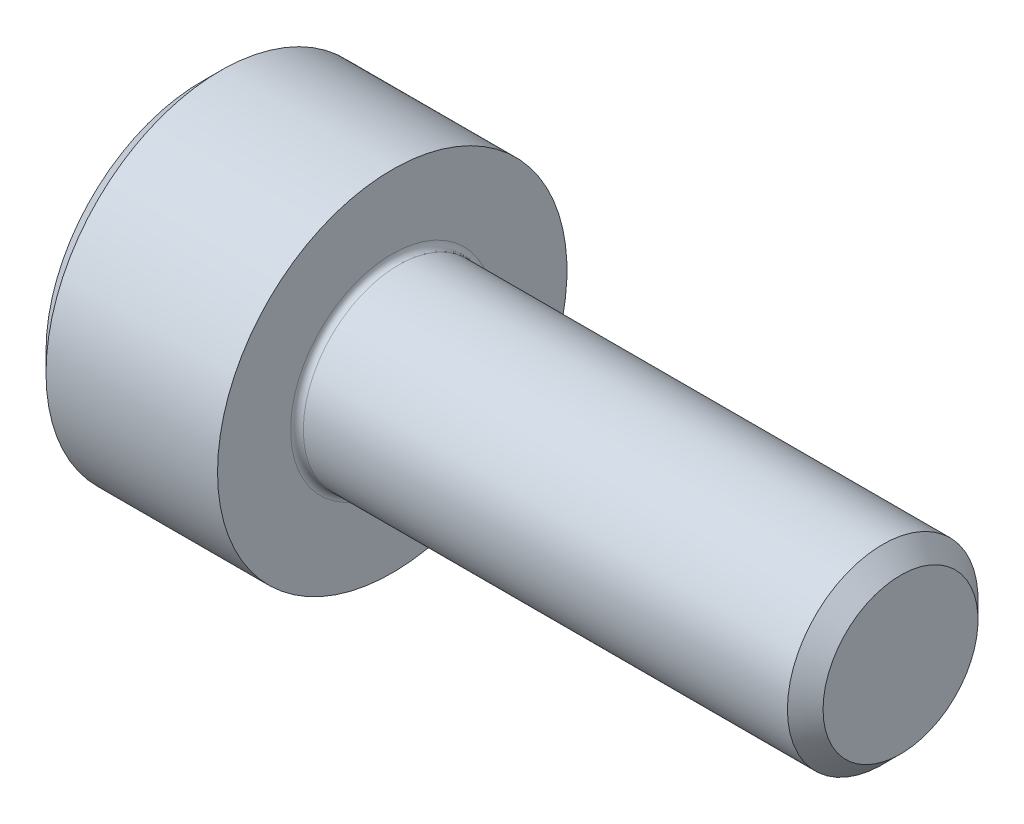
from build123d import *

# Parameters (mm, degrees)
FILLET1_R   = 0.1
HEX_2_DEPTH = 1.3


with BuildPart() as part:
    # BodySke → Base-Revolve (revolve)
    with BuildSketch(Plane.XY):
        Polygon((0, 0), (0, 2.45), (0.3, 2.75), (3, 2.75), (3, 1.5), (10.7195, 1.5), (11, 1.2195), (11, 0), align=None)
    revolve(axis=Axis((-31.75, 0, 0), (1, 0, 0)))

    # Fillet1
    fillet1_edges = [part.edges().sort_by_distance(p)[0] for p in [
        (3, -1.5, 0),
    ]]
    fillet(fillet1_edges, radius=FILLET1_R)

    # Sketch2 → Hex-PreBroach (revolve, cut)
    with BuildSketch(Plane.XY):
        Polygon((0, 1.28), (1.3, 1.28), (2.039008345, 0), (0, 0), align=None)
    revolve(axis=Axis((0, 0, 0), (1, 0, 0)), mode=Mode.SUBTRACT)

    # Sketch3 → Hex 2 (cut)
    with BuildSketch(Plane(origin=(0, 0, 0), x_dir=(0, 0.5, 0.866025404), z_dir=(-1, 0, 0))):
        Polygon((0.739008345, 1.28), (-0.739008345, 1.28), (-1.478016689, 0), (-0.739008345, -1.28), (0.739008345, -1.28), (1.478016689, 0), align=None)
    extrude(amount=-HEX_2_DEPTH, mode=Mode.SUBTRACT)


solid = part.part
